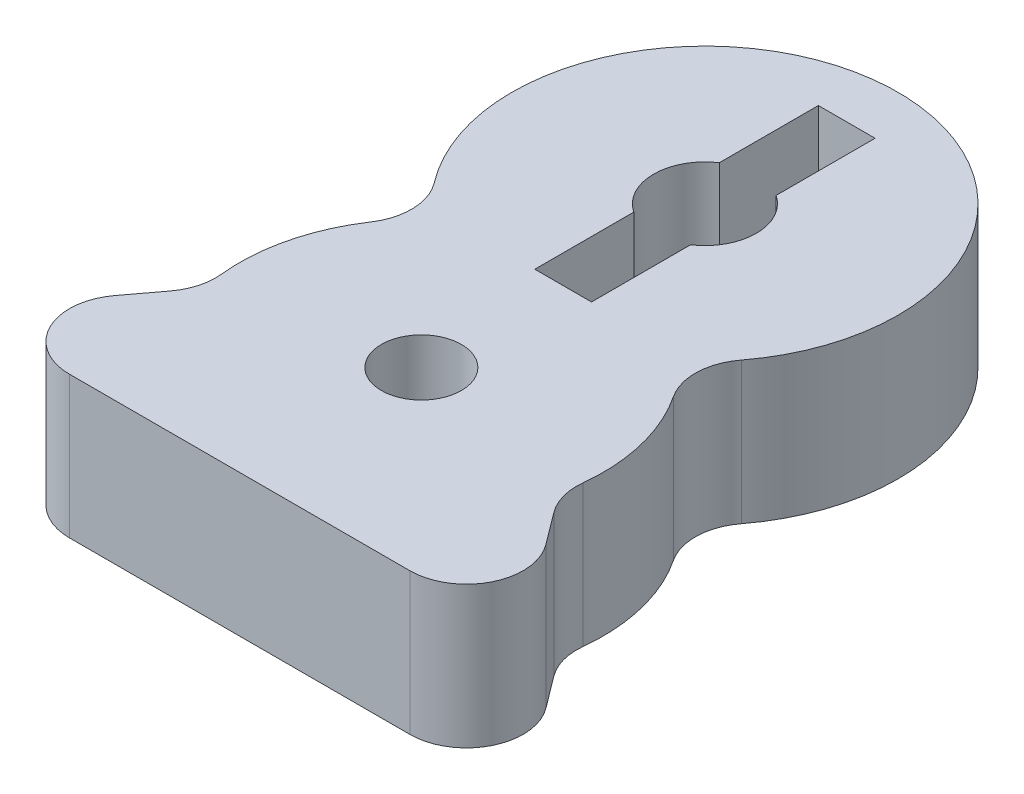
from build123d import *

# Parameters (mm, degrees)
SKETCH1_R           = 1.7907
SKETCH1_R_2         = 2.2987
BOSS_EXTRUDE1_DEPTH = 6.35
FILLET1_R           = 2.54
SKETCH2_W           = 2.54
SKETCH2_H           = 12.7
CUT_EXTRUDE1_DEPTH  = 6.35


with BuildPart() as part:
    # Sketch1 → Boss-Extrude1 (new body)
    with BuildSketch(Plane(origin=(0, 0, 0), x_dir=(1, 0, 0), z_dir=(0, 1, 0))):
        with BuildLine():
            Line((-12.7, -8.1407), (12.7, -8.1407))
            Line((12.7, -8.1407), (7.941309086, -1.7907))
            ThreePointArc((7.941309086, -1.7907), (7.76561659, 2.442579676), (5.48636952, 6.014212))
            ThreePointArc((5.48636952, 6.014212), (0, 21.3487), (-5.48636952, 6.014212))
            ThreePointArc((-5.48636952, 6.014212), (-7.76561659, 2.442579676), (-7.941309086, -1.7907))
            Line((-7.941309086, -1.7907), (-12.7, -8.1407))
        make_face()
        Circle(SKETCH1_R, mode=Mode.SUBTRACT)
        with Locations((0, 12.7)):
            Circle(SKETCH1_R_2, mode=Mode.SUBTRACT)
    extrude(amount=BOSS_EXTRUDE1_DEPTH)

    # Fillet1
    fillet1_edges = [part.edges().sort_by_distance(p)[0] for p in [
        (-7.941309086, 3.175, 1.7907),
        (-5.48636952, 3.175, -6.014212),
        (5.48636952, 3.175, -6.014212),
        (7.941309086, 3.175, 1.7907),
        (12.7, 3.175, 8.1407),
        (-12.7, 3.175, 8.1407),
    ]]
    fillet(fillet1_edges, radius=FILLET1_R)

    # Sketch2 → Cut-Extrude1 (cut)
    with BuildSketch(Plane(origin=(0, 6.35, 0), x_dir=(1, 0, 0), z_dir=(0, 1, 0))):
        with Locations((0, 12.7)):
            Rectangle(SKETCH2_W, SKETCH2_H)
    extrude(amount=-CUT_EXTRUDE1_DEPTH, mode=Mode.SUBTRACT)


solid = part.part
